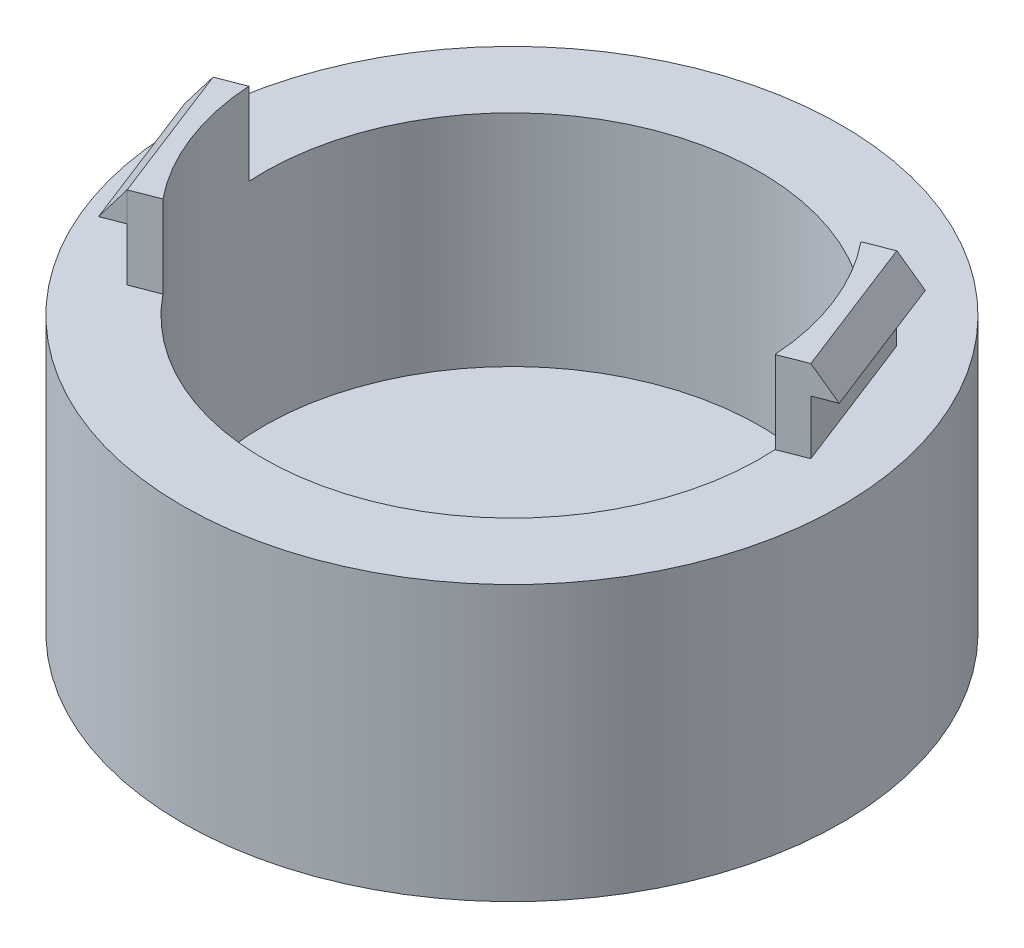
from build123d import *

# Parameters (mm, degrees)
SKETCH1_R            = 15.24
BOSS_EXTRUDE1_DEPTH  = 12.7
BOSS_EXTRUDE10_DEPTH = 3.81
BOSS_EXTRUDE11_DEPTH = 6.989290822
BOSS_EXTRUDE12_DEPTH = 6.985
SKETCH9_R            = 11.477020293
CUT_EXTRUDE3_DEPTH   = 10.16


with BuildPart() as part:
    # Sketch1 → Boss-Extrude1 (new body)
    with BuildSketch(Plane(origin=(0, 0, 0), x_dir=(1, 0, 0), z_dir=(0, 1, 0))):
        Circle(SKETCH1_R)
    extrude(amount=BOSS_EXTRUDE1_DEPTH)

    # Sketch3 → Boss-Extrude10 (add)
    with BuildSketch(Plane(origin=(0, 12.7, 0), x_dir=(1, 0, 0), z_dir=(0, 1, 0))):
        with BuildLine():
            Line((11.427775698, 1.062043977), (12.64550795, 1.175214312))
            Line((12.64550795, 1.175214312), (10.116961472, 7.677049601))
            Line((10.116961472, 7.677049601), (9.142722214, 6.937768036))
            ThreePointArc((9.142722214, 6.937768036), (10.696605975, 4.159881659), (11.427775698, 1.062043977))
        make_face()
        with BuildLine():
            Line((9.142722214, 6.937768036), (10.116961472, 7.677049601))
            Line((10.116961472, 7.677049601), (8.93331892, 7.216734155))
            Line((8.93331892, 7.216734155), (8.94183947, 7.194824647))
            ThreePointArc((8.94183947, 7.194824647), (9.043194256, 7.06701015), (9.142722214, 6.937768036))
        make_face()
        with BuildLine():
            Line((11.461865398, 0.714898867), (12.64550795, 1.175214312))
            Line((12.64550795, 1.175214312), (11.427775698, 1.062043977))
            ThreePointArc((11.427775698, 1.062043977), (11.441715952, 0.899517032), (11.453344849, 0.736808375))
            Line((11.453344849, 0.736808375), (11.461865398, 0.714898867))
        make_face()
        with BuildLine():
            Line((-9.142722214, -6.937768036), (-10.116961472, -7.677049601))
            Line((-10.116961472, -7.677049601), (-8.926355488, -7.214026095))
            ThreePointArc((-8.926355488, -7.214026095), (-9.035594717, -7.076724025), (-9.142722214, -6.937768036))
        make_face()
        with BuildLine():
            Line((-11.427775698, -1.062043977), (-12.64550795, -1.175214312))
            Line((-12.64550795, -1.175214312), (-10.116961472, -7.677049601))
            Line((-10.116961472, -7.677049601), (-9.142722214, -6.937768036))
            ThreePointArc((-9.142722214, -6.937768036), (-10.696605975, -4.159881659), (-11.427775698, -1.062043977))
        make_face()
        with BuildLine():
            Line((-11.454901967, -0.712190807), (-12.64550795, -1.175214312))
            Line((-12.64550795, -1.175214312), (-11.427775698, -1.062043977))
            ThreePointArc((-11.427775698, -1.062043977), (-11.44267598, -0.887221069), (-11.454901967, -0.712190807))
        make_face()
    extrude(amount=BOSS_EXTRUDE10_DEPTH)

    # Sketch6 → Boss-Extrude11 (add)
    with BuildSketch(Plane(origin=(-1.264273239, 0, -3.250917644), x_dir=(-0.932002009, 0, 0.362453107), z_dir=(-0.362453107, 0, -0.932002009))):
        Polygon((12.211598898, 16.51), (12.211598898, 15.157865498), (13.227598898, 15.157865498), align=None)
    extrude(amount=-BOSS_EXTRUDE11_DEPTH)

    # Sketch7 → Boss-Extrude12 (add)
    with BuildSketch(Plane(origin=(1.264273239, 0, 3.250917644), x_dir=(0.932002009, 0, -0.362453107), z_dir=(0.362453107, 0, 0.932002009))):
        Polygon((12.211598898, 16.51), (12.211598898, 15.207573147), (13.227598898, 15.207573147), align=None)
    extrude(amount=-BOSS_EXTRUDE12_DEPTH)

    # Sketch9 → Cut-Extrude3 (cut)
    with BuildSketch(Plane(origin=(0, 12.7, 0), x_dir=(1, 0, 0), z_dir=(0, 1, 0))):
        Circle(SKETCH9_R)
    extrude(amount=-CUT_EXTRUDE3_DEPTH, mode=Mode.SUBTRACT)


solid = part.part
